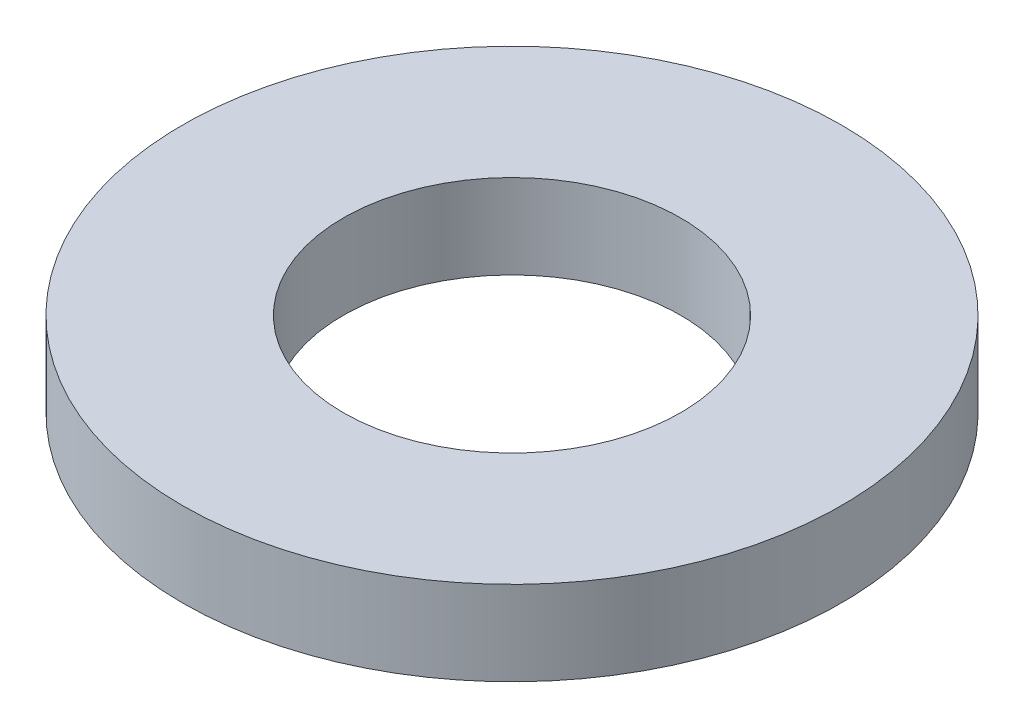
from build123d import *

# Parameters (mm, degrees)
SKETCH1_R           = 6.25
SKETCH1_R_2         = 3.2
BOSS_EXTRUDE1_DEPTH = 1.6


with BuildPart() as part:
    # Sketch1 → Boss-Extrude1 (new body)
    with BuildSketch(Plane(origin=(0, 0, 0), x_dir=(1, 0, 0), z_dir=(0, 1, 0))):
        with Locations(Location((0, 0, 0), (0, 0, 270))):  # turned: the seam where the file's is
            Circle(SKETCH1_R)
        with Locations(Location((0, 0, 0), (0, 0, 270))):  # turned: the seam where the file's is
            Circle(SKETCH1_R_2, mode=Mode.SUBTRACT)
    extrude(amount=BOSS_EXTRUDE1_DEPTH)


solid = part.part
